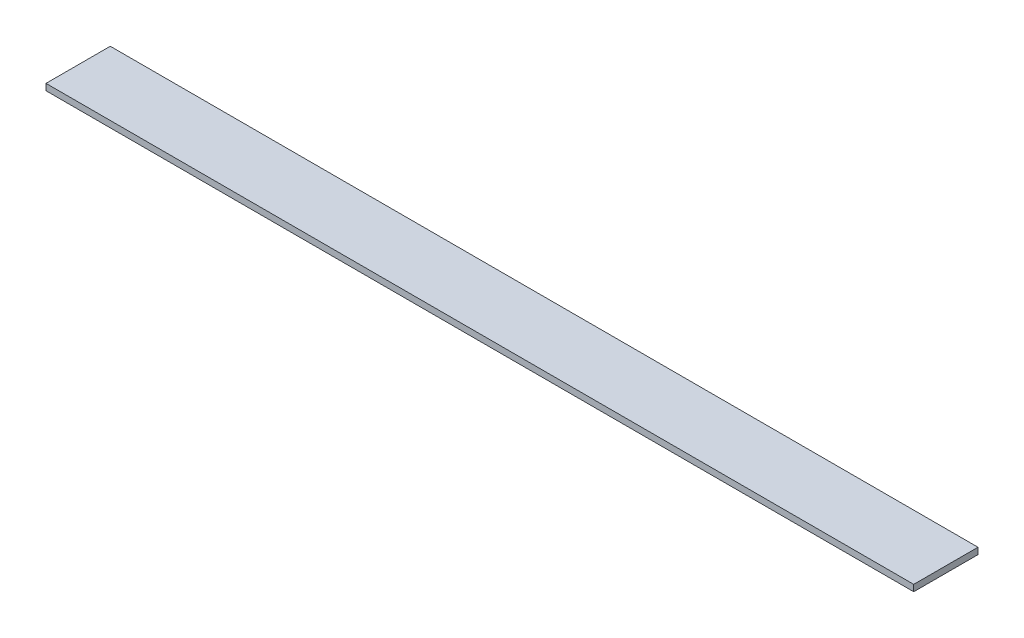
from build123d import *

# Parameters (mm, degrees)
ESQUISSE1_W      = 1350
ESQUISSE1_H      = 100
EXTRUSION1_DEPTH = 10


with BuildPart() as part:
    # Esquisse1 → Extrusion1 (new body)
    with BuildSketch(Plane(origin=(0, 0, 0), x_dir=(1, 0, 0), z_dir=(0, 1, 0))):
        with Locations((675, 50)):
            Rectangle(ESQUISSE1_W, ESQUISSE1_H)
    extrude(amount=EXTRUSION1_DEPTH)


solid = part.part
